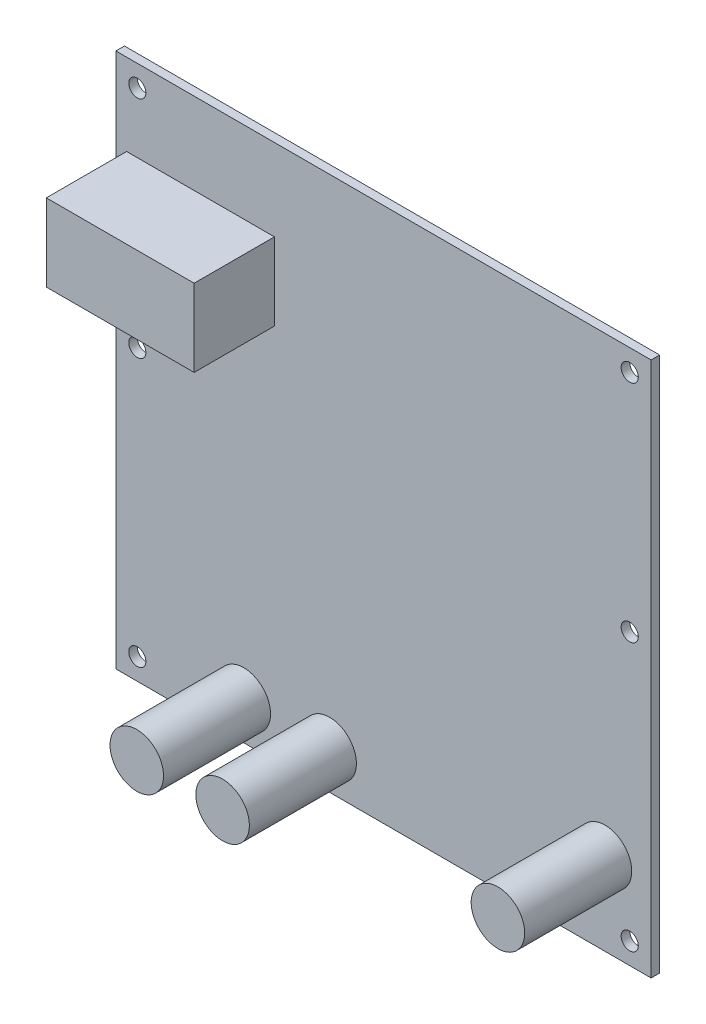
from build123d import *

# Parameters (mm, degrees)
ESQUISSE1_W        = 100
ESQUISSE1_H        = 100
ESQUISSE1_R        = 1.6
BOSS_EXTRU_1_DEPTH = 1.6
ESQUISSE2_R        = 5
BOSS_EXTRU_2_DEPTH = 20
ESQUISSE3_W        = 27.619166331
ESQUISSE3_H        = 14.436937143
BOSS_EXTRU_3_DEPTH = 15


with BuildPart() as part:
    # Esquisse1 → Boss.-Extru.1 (new body)
    with BuildSketch(Plane.XY):
        Rectangle(ESQUISSE1_W, ESQUISSE1_H)
        with Locations((-46, 46)):
            Circle(ESQUISSE1_R, mode=Mode.SUBTRACT)
        with Locations((46, 46)):
            Circle(ESQUISSE1_R, mode=Mode.SUBTRACT)
        with Locations((46, 4)):
            Circle(ESQUISSE1_R, mode=Mode.SUBTRACT)
        with Locations((-46, 4)):
            Circle(ESQUISSE1_R, mode=Mode.SUBTRACT)
        with Locations((-46, -46)):
            Circle(ESQUISSE1_R, mode=Mode.SUBTRACT)
        with Locations((46, -46)):
            Circle(ESQUISSE1_R, mode=Mode.SUBTRACT)
    extrude(amount=BOSS_EXTRU_1_DEPTH)

    # Esquisse2 → Boss.-Extru.2 (add)
    with BuildSketch(Plane.XY.offset(1.6)):
        with Locations((-26.099103373, -42.842866213)):
            Circle(ESQUISSE2_R)
        with Locations((-10.063114572, -42.842866213)):
            Circle(ESQUISSE2_R)
        with Locations((41.376738419, -34.563702957)):
            Circle(ESQUISSE2_R)
    extrude(amount=BOSS_EXTRU_2_DEPTH)

    # Esquisse3 → Boss.-Extru.3 (add)
    with BuildSketch(Plane.XY.offset(1.6)):
        with Locations((-34.191305716, 27.512141018)):
            Rectangle(ESQUISSE3_W, ESQUISSE3_H)
    extrude(amount=BOSS_EXTRU_3_DEPTH)


solid = part.part
